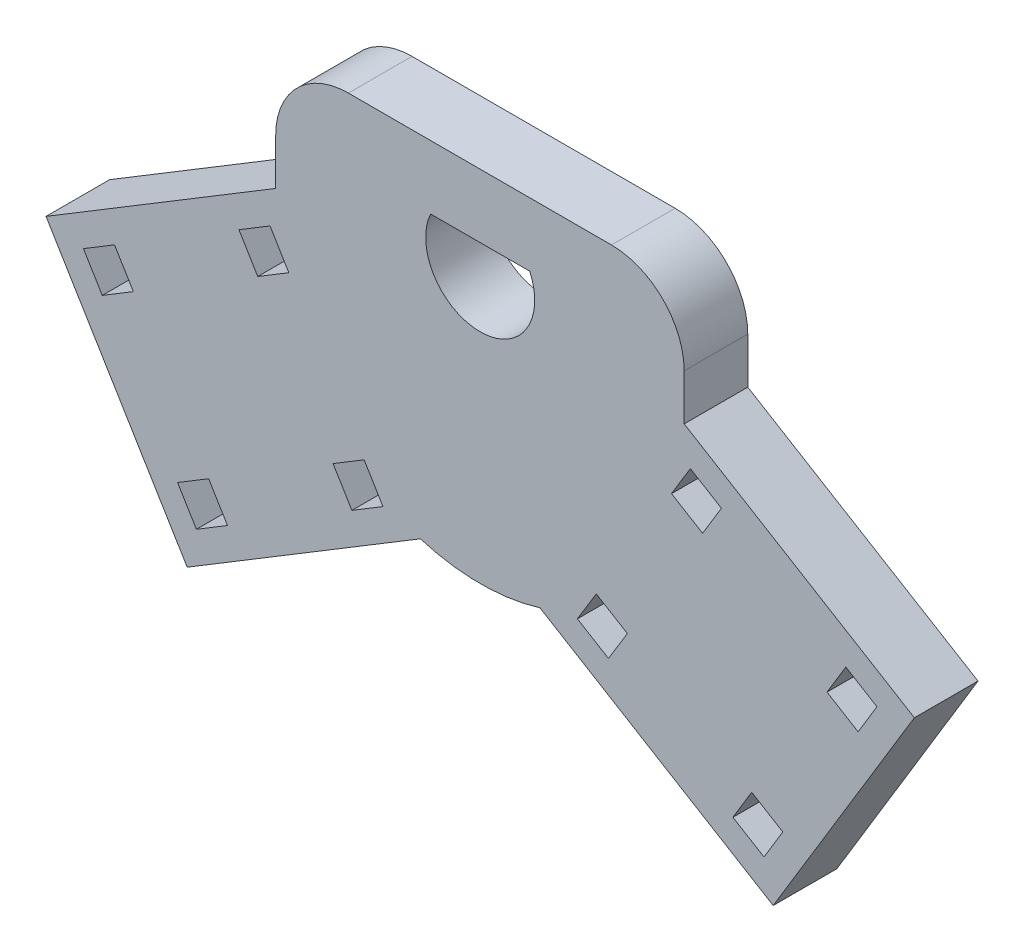
from build123d import *

# Parameters (mm, degrees)
BOSS_EXTRUDE1_DEPTH     = 7
CUT_EXTRUDE1_DEPTH      = 10
CUT_EXTRUDE2_DEPTH      = 10
SKETCH6_W               = 67.896181325
SKETCH6_H               = 26.410991635
CUT_EXTRUDE3_DEPTH      = 8
CUT_EXTRUDE3_DEPTH_BACK = 1
FILLET1_R               = 8


with BuildPart() as part:
    # Sketch2 → Boss-Extrude1 (new body)
    with BuildSketch(Plane.XY):
        with BuildLine():
            Line((47.778278861, -11.389322146), (22.444705062, 3.947002617))
            Line((22.444705062, 3.947002617), (22.444705062, 13.423543635))
            ThreePointArc((22.444705062, 13.423543635), (0.788712907, 37.486172016), (-22.5, 15))
            Line((-22.5, 15), (-22.5, 3.913528416))
            Line((-22.5, 3.913528416), (-47.778278861, -11.389322146))
            Line((-47.778278861, -11.389322146), (-32.24208854, -37.05304733))
            Line((-32.24208854, -37.05304733), (-6.578363356, -21.516857009))
            ThreePointArc((-6.578363356, -21.516857009), (0, -22.5), (6.578363356, -21.516857009))
            Line((6.578363356, -21.516857009), (32.24208854, -37.05304733))
            Line((32.24208854, -37.05304733), (47.778278861, -11.389322146))
        make_face()
    extrude(amount=BOSS_EXTRUDE1_DEPTH)

    # Sketch4 → Cut-Extrude1 (cut)
    with BuildSketch(Plane.XY.offset(7)):
        Polygon((-43.658287311, -12.402075633), (-40.236457286, -10.33058359), (-38.164965243, -13.752413614), (-41.586795268, -15.823905657), align=None)
        Polygon((-23.127307163, 0.026876624), (-26.549137188, -2.044615419), (-24.477645145, -5.466445443), (-21.055815121, -3.3949534), align=None)
        Polygon((-31.229335054, -32.93305578), (-33.300827097, -29.511225755), (-29.878997072, -27.439733712), (-27.807505029, -30.861563737), align=None)
        Polygon((-10.698354907, -20.504103523), (-12.76984695, -17.082273498), (-16.191676974, -19.153765541), (-14.120184931, -22.575595566), align=None)
        Polygon((23.127307163, 0.026876624), (26.549137188, -2.044615419), (24.477645145, -5.466445443), (21.055815121, -3.3949534), align=None)
        Polygon((43.658287311, -12.402075633), (40.236457286, -10.33058359), (38.164965243, -13.752413614), (41.586795268, -15.823905657), align=None)
        Polygon((31.229335054, -32.93305578), (33.300827097, -29.511225755), (29.878997072, -27.439733712), (27.807505029, -30.861563737), align=None)
        Polygon((10.698354907, -20.504103523), (12.76984695, -17.082273498), (16.191676974, -19.153765541), (14.120184931, -22.575595566), align=None)
    extrude(amount=-CUT_EXTRUDE1_DEPTH, mode=Mode.SUBTRACT)

    # Sketch5 → Cut-Extrude2 (cut)
    with BuildSketch(Plane.XY.offset(7)):
        with BuildLine():
            Line((5.454356057, 10), (-5.454356057, 10))
            ThreePointArc((-5.454356057, 10), (0, 1.5), (5.454356057, 10))
        make_face()
    extrude(amount=-CUT_EXTRUDE2_DEPTH, mode=Mode.SUBTRACT)

    # Sketch6 → Cut-Extrude3 (cut, two sides)
    with BuildSketch(Plane.XY) as cut_extrude3_sk:
        with Locations((-0.747480896, 30.205495818)):
            Rectangle(SKETCH6_W, SKETCH6_H)
    extrude(amount=CUT_EXTRUDE3_DEPTH, mode=Mode.SUBTRACT)
    extrude(cut_extrude3_sk.sketch, amount=-CUT_EXTRUDE3_DEPTH_BACK, mode=Mode.SUBTRACT)

    # Fillet1
    fillet1_edges = [part.edges().sort_by_distance(p)[0] for p in [
        (22.410934831, 17, 3.5),
        (-22.410934831, 17, 3.5),
    ]]
    fillet(fillet1_edges, radius=FILLET1_R)


solid = part.part
